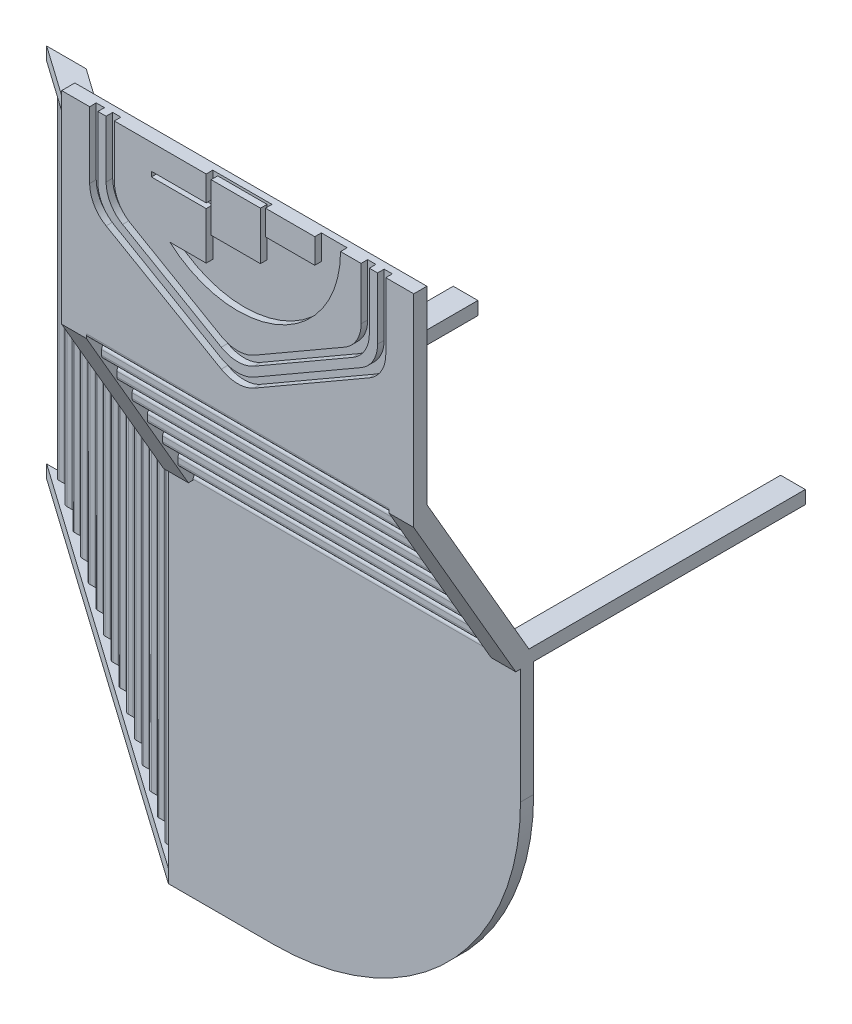
from build123d import *

# Parameters (mm, degrees)
SKETCH1_W               = 2140
SKETCH1_H               = 80
BOSS_EXTRUDE1_DEPTH     = 1150
BOSS_EXTRUDE2_DEPTH     = 150
SKETCH4_W               = 1680
SKETCH4_H               = 80
BOSS_EXTRUDE3_DEPTH     = 150
BOSS_EXTRUDE6_DEPTH     = 150
BOSS_EXTRUDE8_DEPTH     = 1840
BOSS_EXTRUDE9_DEPTH     = 1840
BOSS_EXTRUDE11_DEPTH    = 1840
BOSS_EXTRUDE12_DEPTH    = 1840
BOSS_EXTRUDE13_DEPTH    = 1840
BOSS_EXTRUDE14_DEPTH    = 1840
BOSS_EXTRUDE15_DEPTH    = 1840
SKETCH28_W              = 1680
SKETCH28_H              = 80
BOSS_EXTRUDE16_DEPTH    = 150
BOSS_EXTRUDE20_DEPTH    = 1840
SKETCH34_W              = 2140
SKETCH34_H              = 80
BOSS_EXTRUDE22_DEPTH    = 2200
SKETCH35_W              = 150
SKETCH35_H              = 1680
BOSS_EXTRUDE25_DEPTH    = 80
BOSS_EXTRUDE28_DEPTH    = 80
BOSS_EXTRUDE29_DEPTH    = 80
BOSS_EXTRUDE30_DEPTH    = 2120
BOSS_EXTRUDE31_DEPTH    = 2120
BOSS_EXTRUDE32_DEPTH    = 2120
BOSS_EXTRUDE33_DEPTH    = 2120
BOSS_EXTRUDE34_DEPTH    = 2120
BOSS_EXTRUDE35_DEPTH    = 2120
BOSS_EXTRUDE36_DEPTH    = 2120
BOSS_EXTRUDE37_DEPTH    = 2120
BOSS_EXTRUDE38_DEPTH    = 2120
BOSS_EXTRUDE39_DEPTH    = 2120
BOSS_EXTRUDE40_DEPTH    = 2120
BOSS_EXTRUDE41_DEPTH    = 2120
BOSS_EXTRUDE42_DEPTH    = 2120
BOSS_EXTRUDE43_DEPTH    = 2120
BOSS_EXTRUDE44_DEPTH    = 2120
SKETCH77_W              = 300
SKETCH77_H              = 292.39237422
CUT_EXTRUDE2_DEPTH      = 40
CUT_EXTRUDE3_DEPTH      = 40
CUT_EXTRUDE7_DEPTH      = 5203.403290788
CUT_EXTRUDE7_DEPTH_BACK = 5203.403290788


with BuildPart() as part:
    # Sketch1 → Boss-Extrude1 (new body)
    with BuildSketch(Plane(origin=(0, 0, 0), x_dir=(1, 0, 0), z_dir=(0, 1, 0))):
        Rectangle(SKETCH1_W, SKETCH1_H)
    extrude(amount=BOSS_EXTRUDE1_DEPTH)

    # Sketch3 → Boss-Extrude2 (add)
    with BuildSketch(Plane.ZY.offset(1070)):
        Polygon((-580, -1150), (40, -80), (40, 0), (-40, 0), (-660, -1070), (-660, -1150), align=None)
    extrude(amount=-BOSS_EXTRUDE2_DEPTH)

    # Sketch4 → Boss-Extrude3 (add)
    with BuildSketch(Plane.ZY.offset(1070)):
        with Locations((-1500, -1110)):
            Rectangle(SKETCH4_W, SKETCH4_H)
    extrude(amount=-BOSS_EXTRUDE3_DEPTH)

    # Sketch8 → Boss-Extrude6 (add)
    with BuildSketch(Plane(origin=(1070, 0, 0), x_dir=(0, 0, -1), z_dir=(1, 0, 0))):
        Polygon((-40, 0), (40, 0), (660, -1070), (660, -1150), (580, -1150), (-40, -80), align=None)
    extrude(amount=-BOSS_EXTRUDE6_DEPTH)

    # Sketch16 → Boss-Extrude8 (add)
    with BuildSketch(Plane.ZY.offset(-920)):
        with BuildLine():
            Line((-77.710280374, -160), (-107.710280374, -160))
            ThreePointArc((-107.710280374, -160), (-125.387949903, -167.32233047), (-132.710280374, -185))
            Line((-132.710280374, -185), (-132.710280374, -215))
            ThreePointArc((-132.710280374, -215), (-125.387949903, -232.67766953), (-107.710280374, -240))
            Line((-107.710280374, -240), (-77.710280374, -240))
            ThreePointArc((-77.710280374, -240), (-60.032610844, -232.67766953), (-52.710280374, -215))
            Line((-52.710280374, -215), (-52.710280374, -185))
            ThreePointArc((-52.710280374, -185), (-60.032610844, -167.32233047), (-77.710280374, -160))
        make_face()
    extrude(amount=BOSS_EXTRUDE8_DEPTH)

    # Sketch15 → Boss-Extrude9 (add)
    with BuildSketch(Plane.ZY.offset(-920)):
        with BuildLine():
            Line((40, 0), (-15, 0))
            ThreePointArc((-15, 0), (-32.67766953, -7.32233047), (-40, -25))
            Line((-40, -25), (-40, -55))
            ThreePointArc((-40, -55), (-32.67766953, -72.67766953), (-15, -80))
            Line((-15, -80), (15, -80))
            ThreePointArc((15, -80), (32.67766953, -72.67766953), (40, -55))
            Line((40, -55), (40, 0))
        make_face()
    extrude(amount=BOSS_EXTRUDE9_DEPTH)

    # Sketch17 → Boss-Extrude11 (add)
    with BuildSketch(Plane.ZY.offset(-920)):
        with BuildLine():
            Line((-170.420560748, -320), (-200.420560748, -320))
            ThreePointArc((-200.420560748, -320), (-218.098230277, -327.32233047), (-225.420560748, -345))
            Line((-225.420560748, -345), (-225.420560748, -375))
            ThreePointArc((-225.420560748, -375), (-218.098230277, -392.67766953), (-200.420560748, -400))
            Line((-200.420560748, -400), (-170.420560748, -400))
            ThreePointArc((-170.420560748, -400), (-152.742891218, -392.67766953), (-145.420560748, -375))
            Line((-145.420560748, -375), (-145.420560748, -345))
            ThreePointArc((-145.420560748, -345), (-152.742891218, -327.32233047), (-170.420560748, -320))
        make_face()
    extrude(amount=BOSS_EXTRUDE11_DEPTH)

    # Sketch18 → Boss-Extrude12 (add)
    with BuildSketch(Plane.ZY.offset(-920)):
        with BuildLine():
            Line((-263.130841121, -480), (-293.130841121, -480))
            ThreePointArc((-293.130841121, -480), (-310.808510651, -487.32233047), (-318.130841121, -505))
            Line((-318.130841121, -505), (-318.130841121, -535))
            ThreePointArc((-318.130841121, -535), (-310.808510651, -552.67766953), (-293.130841121, -560))
            Line((-293.130841121, -560), (-263.130841121, -560))
            ThreePointArc((-263.130841121, -560), (-245.453171592, -552.67766953), (-238.130841121, -535))
            Line((-238.130841121, -535), (-238.130841121, -505))
            ThreePointArc((-238.130841121, -505), (-245.453171592, -487.32233047), (-263.130841121, -480))
        make_face()
    extrude(amount=BOSS_EXTRUDE12_DEPTH)

    # Sketch24 → Boss-Extrude13 (add)
    with BuildSketch(Plane.ZY.offset(-920)):
        with BuildLine():
            Line((-355.841121495, -640), (-385.841121495, -640))
            ThreePointArc((-385.841121495, -640), (-403.518791025, -647.32233047), (-410.841121495, -665))
            Line((-410.841121495, -665), (-410.841121495, -695))
            ThreePointArc((-410.841121495, -695), (-403.518791025, -712.67766953), (-385.841121495, -720))
            Line((-385.841121495, -720), (-355.841121495, -720))
            ThreePointArc((-355.841121495, -720), (-338.163451966, -712.67766953), (-330.841121495, -695))
            Line((-330.841121495, -695), (-330.841121495, -665))
            ThreePointArc((-330.841121495, -665), (-338.163451966, -647.32233047), (-355.841121495, -640))
        make_face()
    extrude(amount=BOSS_EXTRUDE13_DEPTH)

    # Sketch25 → Boss-Extrude14 (add)
    with BuildSketch(Plane.ZY.offset(-920)):
        with BuildLine():
            Line((-448.551401869, -800), (-478.551401869, -800))
            ThreePointArc((-478.551401869, -800), (-496.229071399, -807.32233047), (-503.551401869, -825))
            Line((-503.551401869, -825), (-503.551401869, -855))
            ThreePointArc((-503.551401869, -855), (-496.229071399, -872.67766953), (-478.551401869, -880))
            Line((-478.551401869, -880), (-448.551401869, -880))
            ThreePointArc((-448.551401869, -880), (-430.873732339, -872.67766953), (-423.551401869, -855))
            Line((-423.551401869, -855), (-423.551401869, -825))
            ThreePointArc((-423.551401869, -825), (-430.873732339, -807.32233047), (-448.551401869, -800))
        make_face()
    extrude(amount=BOSS_EXTRUDE14_DEPTH)

    # Sketch26 → Boss-Extrude15 (add)
    with BuildSketch(Plane.ZY.offset(-920)):
        with BuildLine():
            Line((-541.261682243, -960), (-571.261682243, -960))
            ThreePointArc((-571.261682243, -960), (-588.939351773, -967.32233047), (-596.261682243, -985))
            Line((-596.261682243, -985), (-596.261682243, -1015))
            ThreePointArc((-596.261682243, -1015), (-588.939351773, -1032.67766953), (-571.261682243, -1040))
            Line((-571.261682243, -1040), (-541.261682243, -1040))
            ThreePointArc((-541.261682243, -1040), (-523.584012713, -1032.67766953), (-516.261682243, -1015))
            Line((-516.261682243, -1015), (-516.261682243, -985))
            ThreePointArc((-516.261682243, -985), (-523.584012713, -967.32233047), (-541.261682243, -960))
        make_face()
    extrude(amount=BOSS_EXTRUDE15_DEPTH)

    # Sketch28 → Boss-Extrude16 (add)
    with BuildSketch(Plane(origin=(1070, 0, 0), x_dir=(0, 0, -1), z_dir=(1, 0, 0))):
        with Locations((1500, -1110)):
            Rectangle(SKETCH28_W, SKETCH28_H)
    extrude(amount=-BOSS_EXTRUDE16_DEPTH)

    # Sketch27 → Boss-Extrude20 (add)
    with BuildSketch(Plane.ZY.offset(-920)):
        with BuildLine():
            Line((-608.971962617, -1150), (-688.971962617, -1150))
            Line((-688.971962617, -1150), (-688.971962617, -1145))
            ThreePointArc((-688.971962617, -1145), (-681.649632146, -1127.32233047), (-663.971962617, -1120))
            Line((-663.971962617, -1120), (-633.971962617, -1120))
            ThreePointArc((-633.971962617, -1120), (-616.294293087, -1127.32233047), (-608.971962617, -1145))
            Line((-608.971962617, -1145), (-608.971962617, -1150))
        make_face()
    extrude(amount=BOSS_EXTRUDE20_DEPTH)

    # Sketch34 → Boss-Extrude22 (add)
    with BuildSketch(Plane(origin=(0, -1150, 0), x_dir=(-1, 0, 0), z_dir=(0, -1, 0))):
        with Locations((0, 648.971962617)):
            Rectangle(SKETCH34_W, SKETCH34_H)
    extrude(amount=BOSS_EXTRUDE22_DEPTH)

    # Sketch35 → Boss-Extrude25 (add)
    with BuildSketch(Plane(origin=(0, -3350, 0), x_dir=(-1, 0, 0), z_dir=(0, -1, 0))):
        with Locations((995, 1528.971962617)):
            Rectangle(SKETCH35_W, SKETCH35_H)
        with Locations((-995, 1528.971962617)):
            Rectangle(SKETCH35_W, SKETCH35_H)
    extrude(amount=-BOSS_EXTRUDE25_DEPTH)

    # Sketch37 → Boss-Extrude28 (add)
    with BuildSketch(Plane(origin=(0, -3350, 0), x_dir=(-1, 0, 0), z_dir=(0, -1, 0))):
        Polygon((1070, 768.971962617), (1070, 608.971962617), (3570, 2368.971962617), (3330, 2368.971962617), align=None)
    extrude(amount=-BOSS_EXTRUDE28_DEPTH)

    # Sketch41 → Boss-Extrude29 (add)
    with BuildSketch(Plane(origin=(0, -1150, 0), x_dir=(-1, 0, 0), z_dir=(0, -1, 0))):
        Polygon((1070, 608.971962617), (3570, 2368.971962617), (3330, 2368.971962617), (1070, 768.971962617), (1070, 688.971962617), align=None)
    extrude(amount=-BOSS_EXTRUDE29_DEPTH)

    # Sketch45 → Boss-Extrude30 (add)
    with BuildSketch(Plane(origin=(0, -3270, 0), x_dir=(1, 0, 0), z_dir=(0, 1, 0))):
        with BuildLine():
            Line((-1175, 813.356727413), (-1205, 813.356727413))
            ThreePointArc((-1205, 813.356727413), (-1222.67766953, 806.034396943), (-1230, 788.356727413))
            Line((-1230, 788.356727413), (-1230, 758.356727413))
            ThreePointArc((-1230, 758.356727413), (-1222.67766953, 740.679057883), (-1205, 733.356727413))
            Line((-1205, 733.356727413), (-1175, 733.356727413))
            ThreePointArc((-1175, 733.356727413), (-1157.32233047, 740.679057883), (-1150, 758.356727413))
            Line((-1150, 758.356727413), (-1150, 788.356727413))
            ThreePointArc((-1150, 788.356727413), (-1157.32233047, 806.034396943), (-1175, 813.356727413))
        make_face()
    extrude(amount=BOSS_EXTRUDE30_DEPTH)

    # Sketch46 → Boss-Extrude31 (add)
    with BuildSketch(Plane(origin=(0, -3270, 0), x_dir=(1, 0, 0), z_dir=(0, 1, 0))):
        with BuildLine():
            Line((-1335, 926.631063696), (-1365, 926.631063696))
            ThreePointArc((-1365, 926.631063696), (-1382.67766953, 919.308733226), (-1390, 901.631063696))
            Line((-1390, 901.631063696), (-1390, 871.631063696))
            ThreePointArc((-1390, 871.631063696), (-1382.67766953, 853.953394167), (-1365, 846.631063696))
            Line((-1365, 846.631063696), (-1335, 846.631063696))
            ThreePointArc((-1335, 846.631063696), (-1317.32233047, 853.953394167), (-1310, 871.631063696))
            Line((-1310, 871.631063696), (-1310, 901.631063696))
            ThreePointArc((-1310, 901.631063696), (-1317.32233047, 919.308733226), (-1335, 926.631063696))
        make_face()
    extrude(amount=BOSS_EXTRUDE31_DEPTH)

    # Sketch48 → Boss-Extrude32 (add)
    with BuildSketch(Plane(origin=(0, -3270, 0), x_dir=(1, 0, 0), z_dir=(0, 1, 0))):
        with BuildLine():
            Line((-1495, 1039.905399979), (-1525, 1039.905399979))
            ThreePointArc((-1525, 1039.905399979), (-1542.67766953, 1032.583069509), (-1550, 1014.905399979))
            Line((-1550, 1014.905399979), (-1550, 984.905399979))
            ThreePointArc((-1550, 984.905399979), (-1542.67766953, 967.22773045), (-1525, 959.905399979))
            Line((-1525, 959.905399979), (-1495, 959.905399979))
            ThreePointArc((-1495, 959.905399979), (-1477.32233047, 967.22773045), (-1470, 984.905399979))
            Line((-1470, 984.905399979), (-1470, 1014.905399979))
            ThreePointArc((-1470, 1014.905399979), (-1477.32233047, 1032.583069509), (-1495, 1039.905399979))
        make_face()
    extrude(amount=BOSS_EXTRUDE32_DEPTH)

    # Sketch55 → Boss-Extrude33 (add)
    with BuildSketch(Plane(origin=(0, -3270, 0), x_dir=(1, 0, 0), z_dir=(0, 1, 0))):
        with BuildLine():
            Line((-1655, 1153.179736263), (-1685, 1153.179736263))
            ThreePointArc((-1685, 1153.179736263), (-1702.67766953, 1145.857405792), (-1710, 1128.179736263))
            Line((-1710, 1128.179736263), (-1710, 1098.179736263))
            ThreePointArc((-1710, 1098.179736263), (-1702.67766953, 1080.502066733), (-1685, 1073.179736263))
            Line((-1685, 1073.179736263), (-1655, 1073.179736263))
            ThreePointArc((-1655, 1073.179736263), (-1637.32233047, 1080.502066733), (-1630, 1098.179736263))
            Line((-1630, 1098.179736263), (-1630, 1128.179736263))
            ThreePointArc((-1630, 1128.179736263), (-1637.32233047, 1145.857405792), (-1655, 1153.179736263))
        make_face()
    extrude(amount=BOSS_EXTRUDE33_DEPTH)

    # Sketch56 → Boss-Extrude34 (add)
    with BuildSketch(Plane(origin=(0, -3270, 0), x_dir=(1, 0, 0), z_dir=(0, 1, 0))):
        with BuildLine():
            Line((-1815, 1266.454072546), (-1845, 1266.454072546))
            ThreePointArc((-1845, 1266.454072546), (-1862.67766953, 1259.131742076), (-1870, 1241.454072546))
            Line((-1870, 1241.454072546), (-1870, 1211.454072546))
            ThreePointArc((-1870, 1211.454072546), (-1862.67766953, 1193.776403016), (-1845, 1186.454072546))
            Line((-1845, 1186.454072546), (-1815, 1186.454072546))
            ThreePointArc((-1815, 1186.454072546), (-1797.32233047, 1193.776403016), (-1790, 1211.454072546))
            Line((-1790, 1211.454072546), (-1790, 1241.454072546))
            ThreePointArc((-1790, 1241.454072546), (-1797.32233047, 1259.131742076), (-1815, 1266.454072546))
        make_face()
    extrude(amount=BOSS_EXTRUDE34_DEPTH)

    # Sketch57 → Boss-Extrude35 (add)
    with BuildSketch(Plane(origin=(0, -3270, 0), x_dir=(1, 0, 0), z_dir=(0, 1, 0))):
        with BuildLine():
            Line((-1975, 1379.728408829), (-2005, 1379.728408829))
            ThreePointArc((-2005, 1379.728408829), (-2022.67766953, 1372.406078359), (-2030, 1354.728408829))
            Line((-2030, 1354.728408829), (-2030, 1324.728408829))
            ThreePointArc((-2030, 1324.728408829), (-2022.67766953, 1307.050739299), (-2005, 1299.728408829))
            Line((-2005, 1299.728408829), (-1975, 1299.728408829))
            ThreePointArc((-1975, 1299.728408829), (-1957.32233047, 1307.050739299), (-1950, 1324.728408829))
            Line((-1950, 1324.728408829), (-1950, 1354.728408829))
            ThreePointArc((-1950, 1354.728408829), (-1957.32233047, 1372.406078359), (-1975, 1379.728408829))
        make_face()
    extrude(amount=BOSS_EXTRUDE35_DEPTH)

    # Sketch58 → Boss-Extrude36 (add)
    with BuildSketch(Plane(origin=(0, -3270, 0), x_dir=(1, 0, 0), z_dir=(0, 1, 0))):
        with BuildLine():
            Line((-2135, 1493.002745112), (-2165, 1493.002745112))
            ThreePointArc((-2165, 1493.002745112), (-2182.67766953, 1485.680414642), (-2190, 1468.002745112))
            Line((-2190, 1468.002745112), (-2190, 1438.002745112))
            ThreePointArc((-2190, 1438.002745112), (-2182.67766953, 1420.325075583), (-2165, 1413.002745112))
            Line((-2165, 1413.002745112), (-2135, 1413.002745112))
            ThreePointArc((-2135, 1413.002745112), (-2117.32233047, 1420.325075583), (-2110, 1438.002745112))
            Line((-2110, 1438.002745112), (-2110, 1468.002745112))
            ThreePointArc((-2110, 1468.002745112), (-2117.32233047, 1485.680414642), (-2135, 1493.002745112))
        make_face()
    extrude(amount=BOSS_EXTRUDE36_DEPTH)

    # Sketch64 → Boss-Extrude37 (add)
    with BuildSketch(Plane(origin=(0, -3270, 0), x_dir=(1, 0, 0), z_dir=(0, 1, 0))):
        with BuildLine():
            Line((-2295, 1606.277081395), (-2325, 1606.277081395))
            ThreePointArc((-2325, 1606.277081395), (-2342.67766953, 1598.954750925), (-2350, 1581.277081395))
            Line((-2350, 1581.277081395), (-2350, 1551.277081395))
            ThreePointArc((-2350, 1551.277081395), (-2342.67766953, 1533.599411866), (-2325, 1526.277081395))
            Line((-2325, 1526.277081395), (-2295, 1526.277081395))
            ThreePointArc((-2295, 1526.277081395), (-2277.32233047, 1533.599411866), (-2270, 1551.277081395))
            Line((-2270, 1551.277081395), (-2270, 1581.277081395))
            ThreePointArc((-2270, 1581.277081395), (-2277.32233047, 1598.954750925), (-2295, 1606.277081395))
        make_face()
    extrude(amount=BOSS_EXTRUDE37_DEPTH)

    # Sketch65 → Boss-Extrude38 (add)
    with BuildSketch(Plane(origin=(0, -3270, 0), x_dir=(1, 0, 0), z_dir=(0, 1, 0))):
        with BuildLine():
            Line((-2455, 1719.551417679), (-2485, 1719.551417679))
            ThreePointArc((-2485, 1719.551417679), (-2502.67766953, 1712.229087208), (-2510, 1694.551417679))
            Line((-2510, 1694.551417679), (-2510, 1664.551417679))
            ThreePointArc((-2510, 1664.551417679), (-2502.67766953, 1646.873748149), (-2485, 1639.551417679))
            Line((-2485, 1639.551417679), (-2455, 1639.551417679))
            ThreePointArc((-2455, 1639.551417679), (-2437.32233047, 1646.873748149), (-2430, 1664.551417679))
            Line((-2430, 1664.551417679), (-2430, 1694.551417679))
            ThreePointArc((-2430, 1694.551417679), (-2437.32233047, 1712.229087208), (-2455, 1719.551417679))
        make_face()
    extrude(amount=BOSS_EXTRUDE38_DEPTH)

    # Sketch73 → Boss-Extrude39 (add)
    with BuildSketch(Plane(origin=(0, -3270, 0), x_dir=(1, 0, 0), z_dir=(0, 1, 0))):
        with BuildLine():
            Line((-3255, 2285.923099095), (-3285, 2285.923099095))
            ThreePointArc((-3285, 2285.923099095), (-3302.67766953, 2278.600768624), (-3310, 2260.923099095))
            Line((-3310, 2260.923099095), (-3310, 2230.923099095))
            ThreePointArc((-3310, 2230.923099095), (-3302.67766953, 2213.245429565), (-3285, 2205.923099095))
            Line((-3285, 2205.923099095), (-3255, 2205.923099095))
            ThreePointArc((-3255, 2205.923099095), (-3237.32233047, 2213.245429565), (-3230, 2230.923099095))
            Line((-3230, 2230.923099095), (-3230, 2260.923099095))
            ThreePointArc((-3230, 2260.923099095), (-3237.32233047, 2278.600768624), (-3255, 2285.923099095))
        make_face()
    extrude(amount=BOSS_EXTRUDE39_DEPTH)

    # Sketch72 → Boss-Extrude40 (add)
    with BuildSketch(Plane(origin=(0, -3270, 0), x_dir=(1, 0, 0), z_dir=(0, 1, 0))):
        with BuildLine():
            Line((-3095, 2172.648762811), (-3125, 2172.648762811))
            ThreePointArc((-3125, 2172.648762811), (-3142.67766953, 2165.326432341), (-3150, 2147.648762811))
            Line((-3150, 2147.648762811), (-3150, 2117.648762811))
            ThreePointArc((-3150, 2117.648762811), (-3142.67766953, 2099.971093282), (-3125, 2092.648762811))
            Line((-3125, 2092.648762811), (-3095, 2092.648762811))
            ThreePointArc((-3095, 2092.648762811), (-3077.32233047, 2099.971093282), (-3070, 2117.648762811))
            Line((-3070, 2117.648762811), (-3070, 2147.648762811))
            ThreePointArc((-3070, 2147.648762811), (-3077.32233047, 2165.326432341), (-3095, 2172.648762811))
        make_face()
    extrude(amount=BOSS_EXTRUDE40_DEPTH)

    # Sketch68 → Boss-Extrude41 (add)
    with BuildSketch(Plane(origin=(0, -3270, 0), x_dir=(1, 0, 0), z_dir=(0, 1, 0))):
        with BuildLine():
            Line((-2935, 2059.374426528), (-2965, 2059.374426528))
            ThreePointArc((-2965, 2059.374426528), (-2982.67766953, 2052.052096058), (-2990, 2034.374426528))
            Line((-2990, 2034.374426528), (-2990, 2004.374426528))
            ThreePointArc((-2990, 2004.374426528), (-2982.67766953, 1986.696756998), (-2965, 1979.374426528))
            Line((-2965, 1979.374426528), (-2935, 1979.374426528))
            ThreePointArc((-2935, 1979.374426528), (-2917.32233047, 1986.696756998), (-2910, 2004.374426528))
            Line((-2910, 2004.374426528), (-2910, 2034.374426528))
            ThreePointArc((-2910, 2034.374426528), (-2917.32233047, 2052.052096058), (-2935, 2059.374426528))
        make_face()
    extrude(amount=BOSS_EXTRUDE41_DEPTH)

    # Sketch67 → Boss-Extrude42 (add)
    with BuildSketch(Plane(origin=(0, -3270, 0), x_dir=(1, 0, 0), z_dir=(0, 1, 0))):
        with BuildLine():
            Line((-2775, 1946.100090245), (-2805, 1946.100090245))
            ThreePointArc((-2805, 1946.100090245), (-2822.67766953, 1938.777759775), (-2830, 1921.100090245))
            Line((-2830, 1921.100090245), (-2830, 1891.100090245))
            ThreePointArc((-2830, 1891.100090245), (-2822.67766953, 1873.422420715), (-2805, 1866.100090245))
            Line((-2805, 1866.100090245), (-2775, 1866.100090245))
            ThreePointArc((-2775, 1866.100090245), (-2757.32233047, 1873.422420715), (-2750, 1891.100090245))
            Line((-2750, 1891.100090245), (-2750, 1921.100090245))
            ThreePointArc((-2750, 1921.100090245), (-2757.32233047, 1938.777759775), (-2775, 1946.100090245))
        make_face()
    extrude(amount=BOSS_EXTRUDE42_DEPTH)

    # Sketch66 → Boss-Extrude43 (add)
    with BuildSketch(Plane(origin=(0, -3270, 0), x_dir=(1, 0, 0), z_dir=(0, 1, 0))):
        with BuildLine():
            Line((-2615, 1832.825753962), (-2645, 1832.825753962))
            ThreePointArc((-2645, 1832.825753962), (-2662.67766953, 1825.503423491), (-2670, 1807.825753962))
            Line((-2670, 1807.825753962), (-2670, 1777.825753962))
            ThreePointArc((-2670, 1777.825753962), (-2662.67766953, 1760.148084432), (-2645, 1752.825753962))
            Line((-2645, 1752.825753962), (-2615, 1752.825753962))
            ThreePointArc((-2615, 1752.825753962), (-2597.32233047, 1760.148084432), (-2590, 1777.825753962))
            Line((-2590, 1777.825753962), (-2590, 1807.825753962))
            ThreePointArc((-2590, 1807.825753962), (-2597.32233047, 1825.503423491), (-2615, 1832.825753962))
        make_face()
    extrude(amount=BOSS_EXTRUDE43_DEPTH)

    # Sketch74 → Boss-Extrude44 (add)
    with BuildSketch(Plane(origin=(0, -3270, 0), x_dir=(1, 0, 0), z_dir=(0, 1, 0))):
        with BuildLine():
            Line((-3390, 2368.971962617), (-3470, 2368.971962617))
            Line((-3470, 2368.971962617), (-3470, 2344.197435378))
            ThreePointArc((-3470, 2344.197435378), (-3462.67766953, 2326.519765848), (-3445, 2319.197435378))
            Line((-3445, 2319.197435378), (-3415, 2319.197435378))
            ThreePointArc((-3415, 2319.197435378), (-3397.32233047, 2326.519765848), (-3390, 2344.197435378))
            Line((-3390, 2344.197435378), (-3390, 2368.971962617))
        make_face()
    extrude(amount=BOSS_EXTRUDE44_DEPTH)

    # Sketch77 → Cut-Extrude2 (cut)
    with BuildSketch(Plane.XY.offset(40)):
        with BuildLine():
            ThreePointArc((-412.766048592, 680.692862691), (257.532735424, 580.524899416), (625, 1150))
            Line((625, 1150), (468.277048619, 1150))
            Line((468.277048619, 1150), (468.277048619, 999.248879328))
            Line((468.277048619, 999.248879328), (168.277048619, 999.248879328))
            Line((168.277048619, 999.248879328), (168.277048619, 1150))
            Line((168.277048619, 1150), (-191.722951381, 1150))
            Line((-191.722951381, 1150), (-191.722951381, 997.749807131))
            Line((-191.722951381, 997.749807131), (-525, 997.749807131))
            Line((-525, 997.749807131), (-525, 967.749807131))
            Line((-525, 967.749807131), (-191.722951381, 967.749807131))
            Line((-191.722951381, 967.749807131), (-191.722951381, 680.692862691))
            Line((-191.722951381, 680.692862691), (-412.766048592, 680.692862691))
        make_face()
        with Locations((-11.722951381, 988.80381289)):
            Rectangle(SKETCH77_W, SKETCH77_H, mode=Mode.SUBTRACT)
    extrude(amount=-CUT_EXTRUDE2_DEPTH, mode=Mode.SUBTRACT)

    # Sketch79 → Cut-Extrude3 (cut)
    with BuildSketch(Plane.XY.offset(40)):
        with BuildLine():
            Line((800, 1150), (750, 1150))
            Line((750, 1150), (750, 832.457351946))
            ThreePointArc((750, 832.457351946), (723.205080757, 732.457351946), (650, 659.252271189))
            Line((650, 659.252271189), (100, 341.709623135))
            ThreePointArc((100, 341.709623135), (0, 314.914703891), (-100, 341.709623135))
            Line((-100, 341.709623135), (-650, 659.252271189))
            ThreePointArc((-650, 659.252271189), (-723.205080757, 732.457351946), (-750, 832.457351946))
            Line((-750, 832.457351946), (-750, 1150))
            Line((-750, 1150), (-800, 1150))
            Line((-800, 1150), (-800, 803.589838486))
            ThreePointArc((-800, 803.589838486), (-773.205080757, 703.589838486), (-700, 630.384757729))
            Line((-700, 630.384757729), (-100, 283.974596216))
            ThreePointArc((-100, 283.974596216), (0, 257.179676972), (100, 283.974596216))
            Line((100, 283.974596216), (700, 630.384757729))
            ThreePointArc((700, 630.384757729), (773.205080757, 703.589838486), (800, 803.589838486))
            Line((800, 803.589838486), (800, 1150))
        make_face()
        with BuildLine():
            Line((900, 1150), (850, 1150))
            Line((850, 1150), (850, 774.722325027))
            ThreePointArc((850, 774.722325027), (823.205080757, 674.722325027), (750, 601.51724427))
            Line((750, 601.51724427), (100, 226.239569297))
            ThreePointArc((100, 226.239569297), (0, 199.444650053), (-100, 226.239569297))
            Line((-100, 226.239569297), (-750, 601.51724427))
            ThreePointArc((-750, 601.51724427), (-823.205080757, 674.722325027), (-850, 774.722325027))
            Line((-850, 774.722325027), (-850, 1150))
            Line((-850, 1150), (-900, 1150))
            Line((-900, 1150), (-900, 745.854811567))
            ThreePointArc((-900, 745.854811567), (-873.205080757, 645.854811567), (-800, 572.64973081))
            Line((-800, 572.64973081), (-100, 168.504542378))
            ThreePointArc((-100, 168.504542378), (0, 141.709623135), (100, 168.504542378))
            Line((100, 168.504542378), (800, 572.64973081))
            ThreePointArc((800, 572.64973081), (873.205080757, 645.854811567), (900, 745.854811567))
            Line((900, 745.854811567), (900, 1150))
        make_face()
    extrude(amount=-CUT_EXTRUDE3_DEPTH, mode=Mode.SUBTRACT)

    # Sketch83 → Cut-Extrude7 (cut, two sides)
    with BuildSketch(Plane.XY.offset(-608.971962617)) as cut_extrude7_sk:
        with BuildLine():
            ThreePointArc((1070, -3100), (996.776695297, -3276.776695297), (820, -3350))
            Line((820, -3350), (1070, -3350))
            Line((1070, -3350), (1070, -3100))
        make_face()
        with BuildLine():
            ThreePointArc((1070, -2850), (923.553390593, -3203.553390593), (570, -3350))
            Line((570, -3350), (820, -3350))
            ThreePointArc((820, -3350), (996.776695297, -3276.776695297), (1070, -3100))
            Line((1070, -3100), (1070, -2850))
        make_face()
        with BuildLine():
            Line((-430, -3350), (-180, -3350))
            ThreePointArc((-180, -3350), (703.883476483, -2983.883476483), (1070, -2100))
            Line((1070, -2100), (1070, -1850))
            ThreePointArc((1070, -1850), (630.66017178, -2910.66017178), (-430, -3350))
        make_face()
        with BuildLine():
            Line((-180, -3350), (0, -3350))
            Line((0, -3350), (70, -3350))
            ThreePointArc((70, -3350), (777.106781187, -3057.106781187), (1070, -2350))
            Line((1070, -2350), (1070, -2247.5))
            Line((1070, -2247.5), (1070, -2100))
            ThreePointArc((1070, -2100), (703.883476483, -2983.883476483), (-180, -3350))
        make_face()
        with BuildLine():
            ThreePointArc((1070, -2350), (777.106781187, -3057.106781187), (70, -3350))
            Line((70, -3350), (320, -3350))
            ThreePointArc((320, -3350), (850.33008589, -3130.33008589), (1070, -2600))
            Line((1070, -2600), (1070, -2350))
        make_face()
        with BuildLine():
            ThreePointArc((1070, -2600), (850.33008589, -3130.33008589), (320, -3350))
            Line((320, -3350), (570, -3350))
            ThreePointArc((570, -3350), (923.553390593, -3203.553390593), (1070, -2850))
            Line((1070, -2850), (1070, -2600))
        make_face()
    extrude(amount=CUT_EXTRUDE7_DEPTH, mode=Mode.SUBTRACT)
    extrude(cut_extrude7_sk.sketch, amount=-CUT_EXTRUDE7_DEPTH_BACK, mode=Mode.SUBTRACT)


solid = part.part
